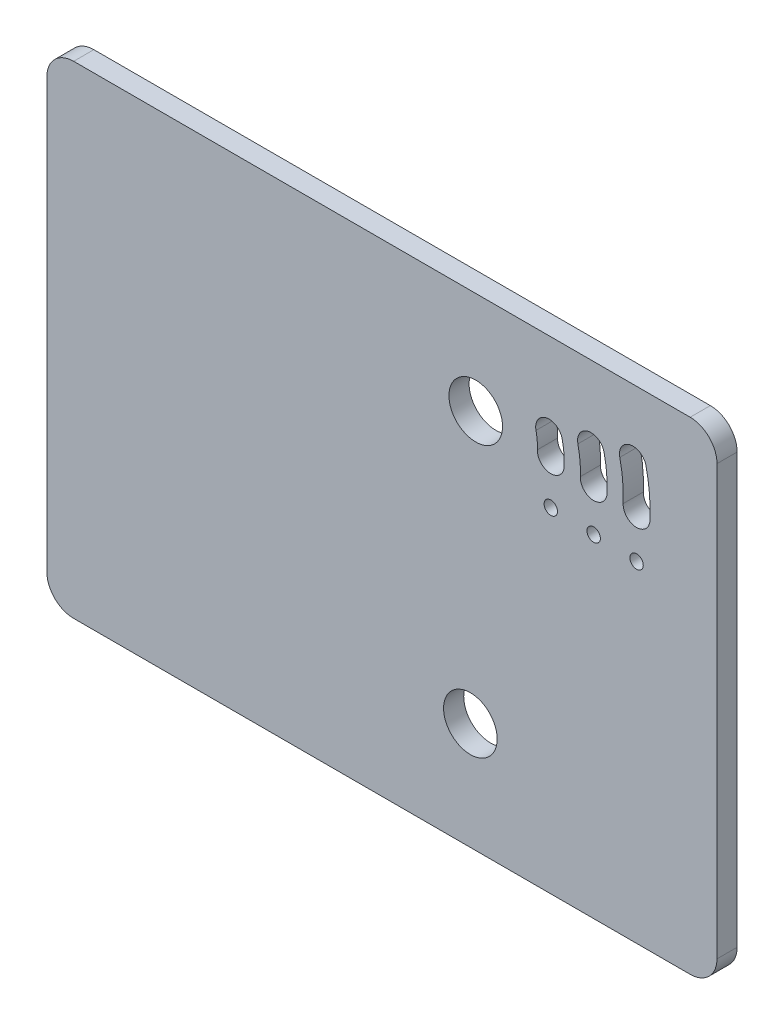
from build123d import *

# Parameters (mm, degrees)
SKETCH1_W           = 158.75
SKETCH1_H           = 114.3
SKETCH1_R           = 6.35
SKETCH1_R_2         = 1.5875
BOSS_EXTRUDE1_DEPTH = 4.7752
FILLET2_R           = 6.35
SKETCH2_R           = 6.35
CUT_EXTRUDE1_DEPTH  = 20.32


with BuildPart() as part:
    # Sketch1 → Boss-Extrude1 (new body)
    with BuildSketch(Plane.XY):
        with Locations((79.375, 57.15)):
            Rectangle(SKETCH1_W, SKETCH1_H)
        with Locations((101.6, 90.17)):
            Circle(SKETCH1_R, mode=Mode.SUBTRACT)
        with Locations((119.38, 79.233708435)):
            Circle(SKETCH1_R_2, mode=Mode.SUBTRACT)
        with Locations((129.54, 78.790113255)):
            Circle(SKETCH1_R_2, mode=Mode.SUBTRACT)
        with Locations((139.7, 78.346518075)):
            Circle(SKETCH1_R_2, mode=Mode.SUBTRACT)
        with BuildLine():
            ThreePointArc((122.551978104, 89.25521688), (122.492134184, 91.997824898), (122.074820056, 94.709158325))
            ThreePointArc((122.074820056, 94.709158325), (118.287884459, 97.121702373), (115.87534041, 93.334766776))
            ThreePointArc((115.87534041, 93.334766776), (116.166297851, 91.444385931), (116.208021896, 89.53219999))
            ThreePointArc((116.208021896, 89.53219999), (119.241508445, 86.221730332), (122.551978104, 89.25521688))
        make_face(mode=Mode.SUBTRACT)
        with BuildLine():
            ThreePointArc((142.871978104, 88.36802652), (142.754095346, 93.7705168), (141.932054608, 99.11140124))
            ThreePointArc((141.932054608, 99.11140124), (138.145119011, 101.523945288), (135.732574962, 97.737009691))
            ThreePointArc((135.732574962, 97.737009691), (136.428259013, 93.217077834), (136.528021896, 88.64500963))
            ThreePointArc((136.528021896, 88.64500963), (139.561508445, 85.334539972), (142.871978104, 88.36802652))
        make_face(mode=Mode.SUBTRACT)
        with BuildLine():
            ThreePointArc((132.711978104, 88.8116217), (132.623114765, 92.884170849), (132.003437332, 96.910279782))
            ThreePointArc((132.003437332, 96.910279782), (128.216501735, 99.322823831), (125.803957686, 95.535888234))
            ThreePointArc((125.803957686, 95.535888234), (126.297278432, 92.330731883), (126.368021896, 89.08860481))
            ThreePointArc((126.368021896, 89.08860481), (129.401508445, 85.778135152), (132.711978104, 88.8116217))
        make_face(mode=Mode.SUBTRACT)
    extrude(amount=BOSS_EXTRUDE1_DEPTH)

    # Fillet2
    fillet2_edges = [part.edges().sort_by_distance(p)[0] for p in [
        (0, 114.3, 2.3876),
        (158.75, 114.3, 2.3876),
        (158.75, 0, 2.3876),
        (0, 0, 2.3876),
    ]]
    fillet(fillet2_edges, radius=FILLET2_R)

    # Sketch2 → Cut-Extrude1 (cut)
    with BuildSketch(Plane.XY.offset(4.7752)):
        with Locations((100.33, 25.4)):
            Circle(SKETCH2_R)
    extrude(amount=-CUT_EXTRUDE1_DEPTH, mode=Mode.SUBTRACT)


solid = part.part
